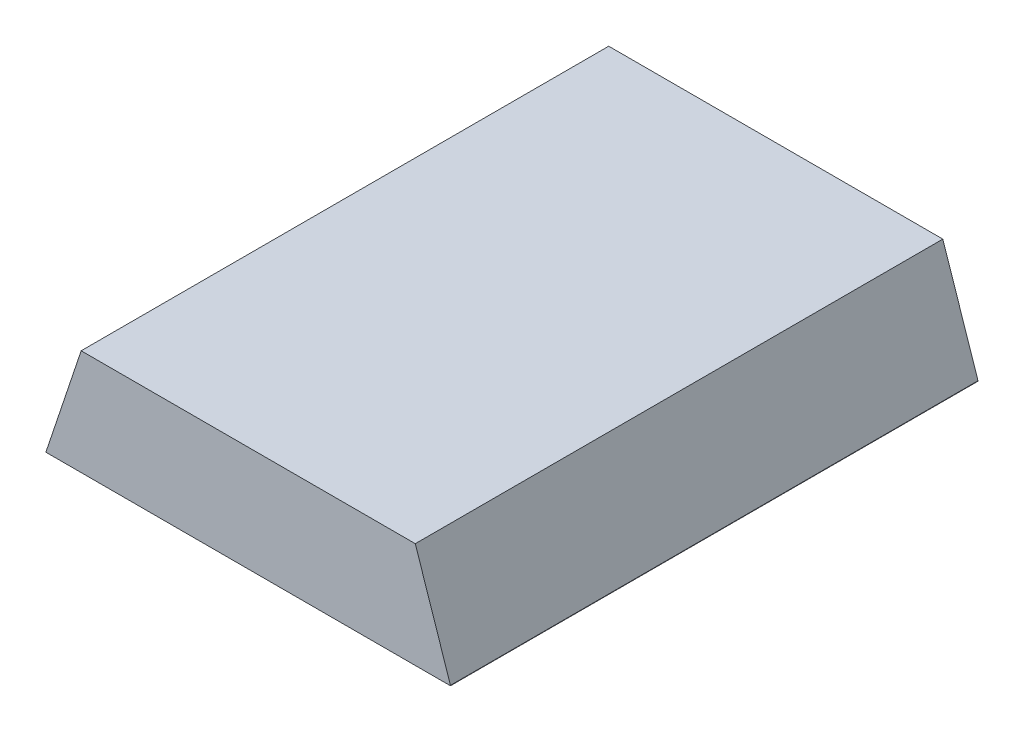
from build123d import *

# Parameters (mm, degrees)
SKETCH_1_W      = 1.15
SKETCH_1_H      = 1.5
EXTRUDE_1_DEPTH = 0.3
CHAMFER_1_SIZE  = 0.1
CHAMFER_1_SIZE2 = 0.298868496
CHAMFER_2_SIZE  = 0.1
CHAMFER_2_SIZE2 = 0.298868496


with BuildPart() as part:
    # 草图1 → 凸台-拉伸1 (new body)
    with BuildSketch(Plane(origin=(0, 0, 0), x_dir=(1, 0, 0), z_dir=(0, 1, 0))):
        Rectangle(SKETCH_1_W, SKETCH_1_H)
    extrude(amount=EXTRUDE_1_DEPTH)

    # 倒角1
    chamfer_1_edges = [part.edges().sort_by_distance(p)[0] for p in [
        (-0.575, 0.3, 0),
    ]]
    chamfer_1_side = [part.faces().sort_by_distance(p)[0] for p in [
        (0, 0.3, 0),
    ]]
    chamfer(chamfer_1_edges, length=CHAMFER_1_SIZE, length2=CHAMFER_1_SIZE2, reference=chamfer_1_side[0])

    # 倒角2
    chamfer_2_edges = [part.edges().sort_by_distance(p)[0] for p in [
        (0.575, 0.3, 0),
    ]]
    chamfer_2_side = [part.faces().sort_by_distance(p)[0] for p in [
        (0.05, 0.3, 0),
    ]]
    chamfer(chamfer_2_edges, length=CHAMFER_2_SIZE, length2=CHAMFER_2_SIZE2, reference=chamfer_2_side[0])


solid = part.part
